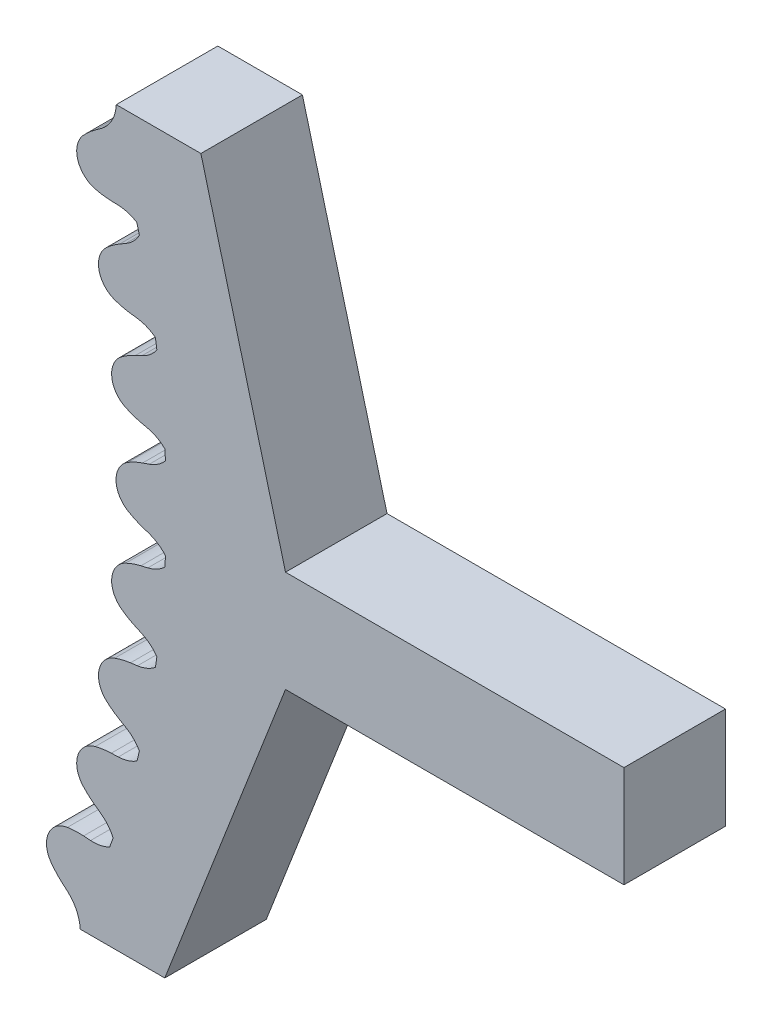
from build123d import *

# Parameters (mm, degrees)
BOSS_EXTRUDE1_DEPTH = 7.62


with BuildPart() as part:
    # Sketch1 → Boss-Extrude1 (new body)
    with BuildSketch(Plane.XY):
        with BuildLine():
            Line((73.084670889, 24.389207851), (79.434670889, 0.351172556))
            Line((79.434670889, 0.351172556), (104.834670889, 0.351172556))
            Line((104.834670889, 0.351172556), (104.834670889, -7.268827444))
            Line((104.834670889, -7.268827444), (79.434670889, -7.268827444))
            Line((79.434670889, -7.268827444), (70.374307571, -30.552841702))
            Line((70.374307571, -30.552841702), (64.024307571, -30.552841702))
            ThreePointArc((64.024307571, -30.552841702), (63.754976443, -29.466421477), (63.079810248, -28.573673602))
            Line((63.079810248, -28.573673602), (62.683021764, -28.224932994))
            ThreePointArc((62.683021764, -28.224932994), (62.247675801, -27.79943175), (61.859720198, -27.330317834))
            ThreePointArc((61.859720198, -27.330317834), (61.688197961, -27.049614145), (61.569433036, -26.742841702))
            ThreePointArc((61.569433036, -26.742841702), (61.63789275, -25.531251133), (62.446208329, -24.626118898))
            ThreePointArc((62.446208329, -24.626118898), (62.747108688, -24.493177507), (63.066880707, -24.415974562))
            ThreePointArc((63.066880707, -24.415974562), (63.672920376, -24.358586969), (64.281631273, -24.365548236))
            Line((64.281631273, -24.365548236), (64.80879995, -24.399523215))
            ThreePointArc((64.80879995, -24.399523215), (65.544016286, -24.349243284), (66.240331439, -24.107962657))
            ThreePointArc((66.240331439, -24.107962657), (66.370344576, -23.747689015), (66.498398241, -23.386714262))
            ThreePointArc((66.498398241, -23.386714262), (66.113206158, -22.758464159), (65.576773496, -22.253180941))
            Line((65.576773496, -22.253180941), (65.147713099, -21.945011687))
            ThreePointArc((65.147713099, -21.945011687), (64.672757031, -21.564230714), (64.240688336, -21.135402009))
            ThreePointArc((64.240688336, -21.135402009), (64.042478252, -20.872862103), (63.894216256, -20.579207851))
            ThreePointArc((63.894216256, -20.579207851), (63.843589674, -19.366741197), (64.55929452, -18.38673864))
            ThreePointArc((64.55929452, -18.38673864), (64.845715425, -18.224944005), (65.156380444, -18.116769674))
            ThreePointArc((65.156380444, -18.116769674), (65.753876898, -18.000256143), (66.360339009, -17.947519788))
            Line((66.360339009, -17.947519788), (66.888299355, -17.929659602))
            ThreePointArc((66.888299355, -17.929659602), (67.615047129, -17.80755798), (68.284359697, -17.499188365))
            ThreePointArc((68.284359697, -17.499188365), (68.378433792, -17.127906023), (68.470489131, -16.756118009))
            ThreePointArc((68.470489131, -16.756118009), (68.025572575, -16.168648528), (67.442196566, -15.718377982))
            Line((67.442196566, -15.718377982), (66.984996344, -15.45374792))
            ThreePointArc((66.984996344, -15.45374792), (66.475004257, -15.121354347), (66.002983527, -14.736940707))
            ThreePointArc((66.002983527, -14.736940707), (65.779994468, -14.495092989), (65.603663244, -14.21738498))
            ThreePointArc((65.603663244, -14.21738498), (65.43443793, -13.015718957), (66.050639412, -11.970284037))
            ThreePointArc((66.050639412, -11.970284037), (66.319822476, -11.781194329), (66.618388618, -11.643090391))
            ThreePointArc((66.618388618, -11.643090391), (67.20158764, -11.46857301), (67.799960404, -11.356646914))
            Line((67.799960404, -11.356646914), (68.323627873, -11.287123566))
            ThreePointArc((68.323627873, -11.287123566), (69.034908105, -11.094376158), (69.670772242, -10.721887324))
            ThreePointArc((69.670772242, -10.721887324), (69.728001312, -10.343171934), (69.783171782, -9.964151179))
            ThreePointArc((69.783171782, -9.964151179), (69.282815542, -9.423119973), (68.658114417, -9.032198451))
            Line((68.658114417, -9.032198451), (68.177177456, -8.813656114))
            ThreePointArc((68.177177456, -8.813656114), (67.637060853, -8.532851072), (67.129633907, -8.196554611))
            ThreePointArc((67.129633907, -8.196554611), (66.884013379, -7.977728206), (66.681311093, -7.718640919))
            ThreePointArc((66.681311093, -7.718640919), (66.395116777, -6.539348227), (66.90588054, -5.438549056))
            ThreePointArc((66.90588054, -5.438549056), (67.155233381, -5.223985312), (67.438825293, -5.057281783))
            ThreePointArc((67.438825293, -5.057281783), (68.002110358, -4.82644125), (68.586631118, -4.656403321))
            Line((68.586631118, -4.656403321), (69.100962504, -4.53588636))
            ThreePointArc((69.100962504, -4.53588636), (69.789925178, -4.274349429), (70.386217165, -3.841328646))
            ThreePointArc((70.386217165, -3.841328646), (70.406050062, -3.458827444), (70.42380434, -3.076224127))
            ThreePointArc((70.42380434, -3.076224127), (69.872827121, -2.586841621), (69.212817092, -2.259033911))
            Line((69.212817092, -2.259033911), (68.71277508, -2.08868398))
            ThreePointArc((68.71277508, -2.08868398), (68.147735579, -1.862171777), (67.609789215, -1.577231214))
            ThreePointArc((67.609789215, -1.577231214), (67.343902678, -1.383533539), (67.116781464, -1.145562126))
            ThreePointArc((67.116781464, -1.145562126), (66.716374355, 0), (67.116781464, 1.145562126))
            ThreePointArc((67.116781464, 1.145562126), (67.343902678, 1.383533539), (67.609789215, 1.577231214))
            ThreePointArc((67.609789215, 1.577231214), (68.147735579, 1.862171777), (68.71277508, 2.08868398))
            Line((68.71277508, 2.08868398), (69.212817092, 2.259033911))
            ThreePointArc((69.212817092, 2.259033911), (69.872827121, 2.586841621), (70.42380434, 3.076224127))
            ThreePointArc((70.42380434, 3.076224127), (70.406050062, 3.458827444), (70.386217165, 3.841328646))
            ThreePointArc((70.386217165, 3.841328646), (69.789925178, 4.274349429), (69.100962504, 4.53588636))
            Line((69.100962504, 4.53588636), (68.586631118, 4.656403321))
            ThreePointArc((68.586631118, 4.656403321), (68.002110358, 4.82644125), (67.438825293, 5.057281783))
            ThreePointArc((67.438825293, 5.057281783), (67.155233381, 5.223985312), (66.90588054, 5.438549056))
            ThreePointArc((66.90588054, 5.438549056), (66.395116777, 6.539348227), (66.681311093, 7.718640919))
            ThreePointArc((66.681311093, 7.718640919), (66.884013379, 7.977728206), (67.129633907, 8.196554611))
            ThreePointArc((67.129633907, 8.196554611), (67.637060853, 8.532851072), (68.177177456, 8.813656114))
            Line((68.177177456, 8.813656114), (68.658114417, 9.032198451))
            ThreePointArc((68.658114417, 9.032198451), (69.282815542, 9.423119973), (69.783171782, 9.964151179))
            ThreePointArc((69.783171782, 9.964151179), (69.728001312, 10.343171934), (69.670772242, 10.721887324))
            ThreePointArc((69.670772242, 10.721887324), (69.034908105, 11.094376158), (68.323627873, 11.287123566))
            Line((68.323627873, 11.287123566), (67.799960404, 11.356646914))
            ThreePointArc((67.799960404, 11.356646914), (67.20158764, 11.46857301), (66.618388618, 11.643090391))
            ThreePointArc((66.618388618, 11.643090391), (66.319822476, 11.781194329), (66.050639412, 11.970284037))
            ThreePointArc((66.050639412, 11.970284037), (65.43443793, 13.015718957), (65.603663244, 14.21738498))
            ThreePointArc((65.603663244, 14.21738498), (65.779994468, 14.495092989), (66.002983527, 14.736940707))
            ThreePointArc((66.002983527, 14.736940707), (66.475004257, 15.121354347), (66.984996344, 15.45374792))
            Line((66.984996344, 15.45374792), (67.442196566, 15.718377982))
            ThreePointArc((67.442196566, 15.718377982), (68.025572575, 16.168648528), (68.470489131, 16.756118009))
            ThreePointArc((68.470489131, 16.756118009), (68.378433792, 17.127906023), (68.284359697, 17.499188365))
            ThreePointArc((68.284359697, 17.499188365), (67.615047129, 17.80755798), (66.888299355, 17.929659602))
            Line((66.888299355, 17.929659602), (66.360339009, 17.947519788))
            ThreePointArc((66.360339009, 17.947519788), (65.753876898, 18.000256143), (65.156380444, 18.116769674))
            ThreePointArc((65.156380444, 18.116769674), (64.845715425, 18.224944005), (64.55929452, 18.38673864))
            ThreePointArc((64.55929452, 18.38673864), (63.843589674, 19.366741197), (63.894216256, 20.579207851))
            ThreePointArc((63.894216256, 20.579207851), (64.042478252, 20.872862103), (64.240688336, 21.135402009))
            ThreePointArc((64.240688336, 21.135402009), (64.672757031, 21.564230714), (65.147713099, 21.945011687))
            Line((65.147713099, 21.945011687), (65.576773496, 22.253180941))
            ThreePointArc((65.576773496, 22.253180941), (66.400832851, 23.188324819), (66.734670889, 24.389207851))
            Line((66.734670889, 24.389207851), (73.084670889, 24.389207851))
        make_face()
    extrude(amount=BOSS_EXTRUDE1_DEPTH)


solid = part.part
